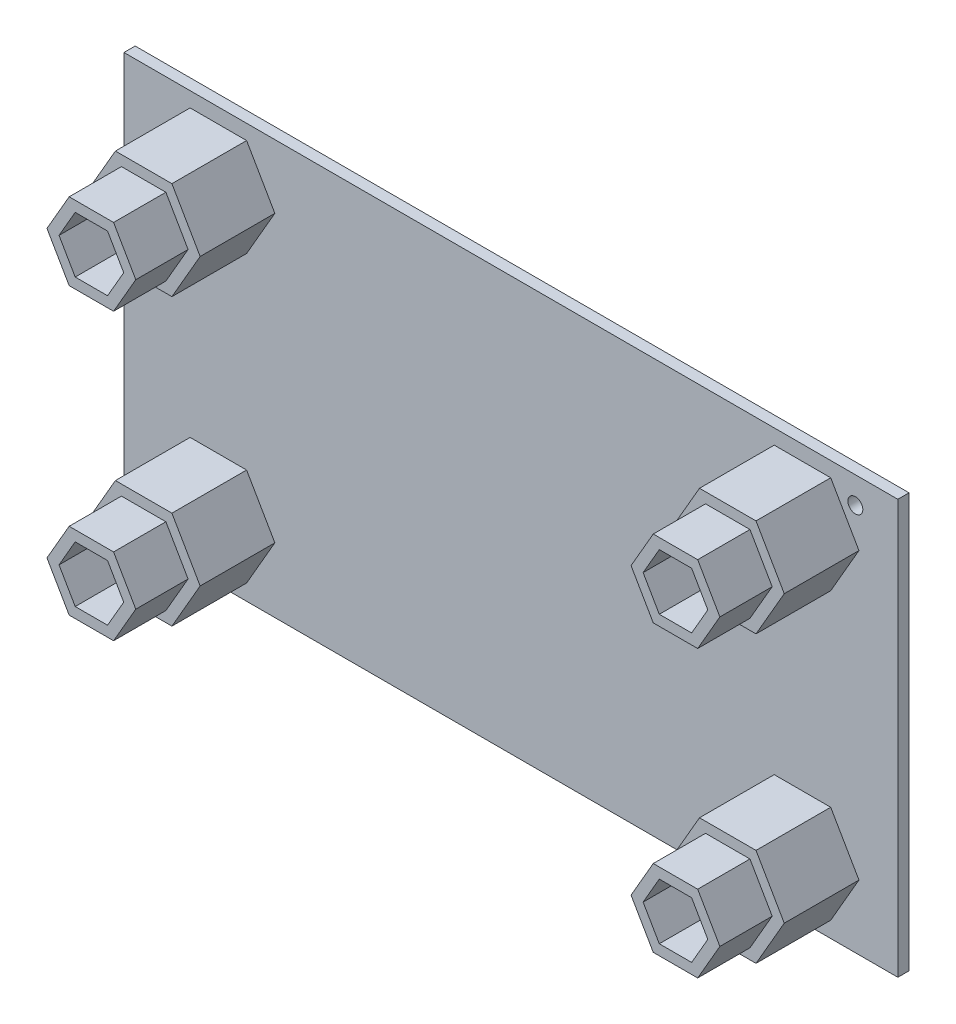
from build123d import *

# Parameters (mm, degrees)
SKETCH1_W           = 103.6
SKETCH1_H           = 55.42
BOSS_EXTRUDE1_DEPTH = 1.5
SKETCH2_R           = 1
CUT_EXTRUDE1_DEPTH  = 1.5
BOSS_EXTRUDE2_DEPTH = 17
BOSS_EXTRUDE4_DEPTH = 10
CUT_EXTRUDE2_DEPTH  = 15


with BuildPart() as part:
    # Sketch1 → Boss-Extrude1 (new body)
    with BuildSketch(Plane.XY):
        with Locations((51.8, 27.71)):
            Rectangle(SKETCH1_W, SKETCH1_H)
    extrude(amount=BOSS_EXTRUDE1_DEPTH)

    # Sketch2 → Cut-Extrude1 (cut)
    with BuildSketch(Plane(origin=(0, 0, 0), x_dir=(-1, 0, 0), z_dir=(0, 0, -1))):
        with Locations((-90.42, 3.54)):
            Circle(SKETCH2_R)
        with Locations((-15.28, 3.54)):
            Circle(SKETCH2_R)
        with Locations((-97.91, 51.88)):
            Circle(SKETCH2_R)
        with Locations((-15.28, 51.88)):
            Circle(SKETCH2_R)
    extrude(amount=-CUT_EXTRUDE1_DEPTH, mode=Mode.SUBTRACT)

    # Sketch3 → Boss-Extrude2 (add)
    with BuildSketch(Plane.XY.offset(1.5)):
        Polygon((9.663353886, 41.72), (15.610061659, 41.72), (18.583415545, 46.87), (15.610061659, 52.02), (9.663353886, 52.02), (6.69, 46.87), align=None)
        Polygon((6.69, 8.67), (9.663353886, 13.82), (15.610061659, 13.82), (18.583415545, 8.67), (15.610061659, 3.52), (9.663353886, 3.52), align=None)
        Polygon((96.776831091, 46.87), (93.803477204, 41.72), (87.856769432, 41.72), (84.883415545, 46.87), (87.856769432, 52.02), (93.803477204, 52.02), align=None)
        Polygon((93.803477204, 13.82), (87.856769432, 13.82), (84.883415545, 8.67), (87.856769432, 3.52), (93.803477204, 3.52), (96.776831091, 8.67), align=None)
    extrude(amount=BOSS_EXTRUDE2_DEPTH)

    # Sketch4 → Boss-Extrude4 (add)
    with BuildSketch(Plane.XY.offset(1.5)):
        Polygon((20.199996299, 46.87), (17.267876695, 51.948580128), (16.418352036, 53.42), (14.289848496, 53.42), (8.855063509, 53.42), (5.073419246, 46.87), (8.855063509, 40.32), (16.418352036, 40.32), align=None)
        Polygon((18.583415545, 46.87), (16.05544113, 51.248580128), (15.610061659, 52.02), (14.289848496, 52.02), (9.663353886, 52.02), (6.69, 46.87), (9.663353886, 41.72), (15.610061659, 41.72), align=None, mode=Mode.SUBTRACT)
        Polygon((8.855063509, 2.12), (14.28020002, 2.12), (16.418352036, 2.12), (17.226260541, 3.519338579), (20.199996299, 8.67), (16.418352036, 15.22), (8.855063509, 15.22), (5.073419246, 8.67), align=None)
        Polygon((9.663353886, 3.52), (14.28020002, 3.52), (15.610061659, 3.52), (16.013824976, 4.219338579), (18.583415545, 8.67), (15.610061659, 13.82), (9.663353886, 13.82), (6.69, 8.67), align=None, mode=Mode.SUBTRACT)
        Polygon((83.266834792, 8.67), (87.048479055, 2.12), (89.42020002, 2.12), (91.41979998, 2.12), (94.611767581, 2.12), (98.393411844, 8.67), (94.611767581, 15.22), (87.048479055, 15.22), align=None)
        Polygon((84.883415545, 8.67), (87.856769432, 3.52), (89.42020002, 3.52), (91.41979998, 3.52), (93.803477204, 3.52), (96.776831091, 8.67), (93.803477204, 13.82), (87.856769432, 13.82), align=None, mode=Mode.SUBTRACT)
        Polygon((98.393411844, 46.87), (94.611767581, 53.42), (87.048479055, 53.42), (83.266834792, 46.87), (87.048479055, 40.32), (94.611767581, 40.32), align=None)
        Polygon((96.776831091, 46.87), (93.803477204, 52.02), (87.856769432, 52.02), (84.883415545, 46.87), (87.856769432, 41.72), (93.803477204, 41.72), align=None, mode=Mode.SUBTRACT)
    extrude(amount=BOSS_EXTRUDE4_DEPTH)

    # Sketch5 → Cut-Extrude2 (cut)
    with BuildSketch(Plane.XY.offset(18.5)):
        Polygon((14.801771282, 50.62), (10.471644263, 50.62), (8.306580754, 46.87), (10.471644263, 43.12), (14.801771282, 43.12), (16.966834792, 46.87), align=None)
        Polygon((88.665059808, 43.12), (92.995186827, 43.12), (95.160250337, 46.87), (92.995186827, 50.62), (88.665059808, 50.62), (86.499996299, 46.87), align=None)
        Polygon((88.665059808, 4.92), (92.995186827, 4.92), (95.160250337, 8.67), (92.995186827, 12.42), (88.665059808, 12.42), (86.499996299, 8.67), align=None)
        Polygon((14.801771282, 12.42), (10.471644263, 12.42), (8.306580754, 8.67), (10.471644263, 4.92), (14.801771282, 4.92), (16.966834792, 8.67), align=None)
    extrude(amount=-CUT_EXTRUDE2_DEPTH, mode=Mode.SUBTRACT)


solid = part.part
